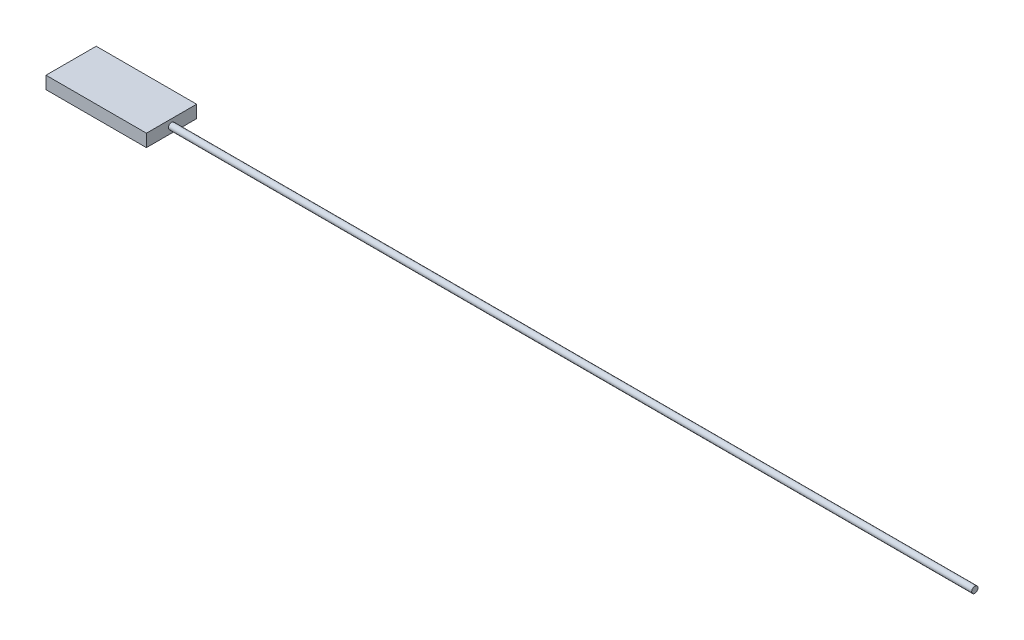
from build123d import *

# Parameters (mm, degrees)
SKETCH1_W           = 50.8
SKETCH1_H           = 25.4
BOSS_EXTRUDE1_DEPTH = 6.35
SKETCH2_R           = 1.5875
BOSS_EXTRUDE2_DEPTH = 406.4


with BuildPart() as part:
    # Sketch1 → Boss-Extrude1 (new body)
    with BuildSketch(Plane(origin=(0, 0, 0), x_dir=(1, 0, 0), z_dir=(0, 1, 0))):
        Rectangle(SKETCH1_W, SKETCH1_H)
    extrude(amount=BOSS_EXTRUDE1_DEPTH)

    # Sketch2 → Boss-Extrude2 (add)
    with BuildSketch(Plane(origin=(25.4, 0, 0), x_dir=(0, 0, -1), z_dir=(1, 0, 0))):
        with Locations((0, 3.175)):
            Circle(SKETCH2_R)
    extrude(amount=BOSS_EXTRUDE2_DEPTH)


solid = part.part
